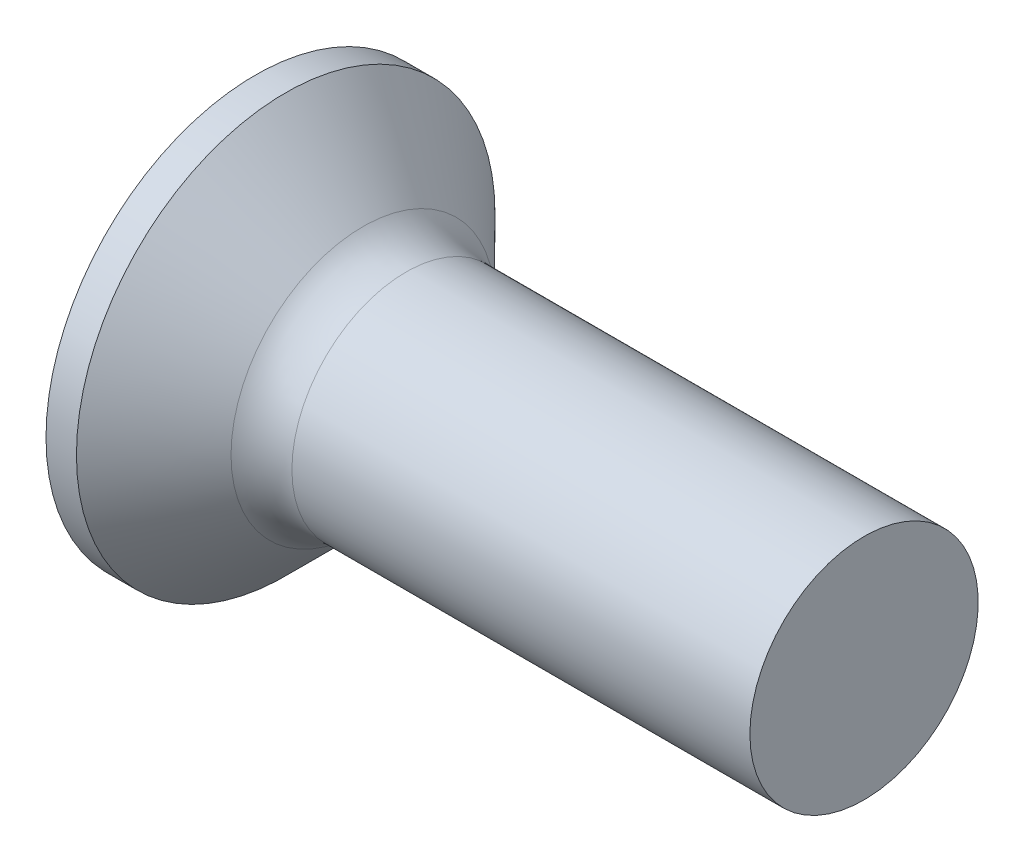
from build123d import *

# Parameters (mm, degrees)
FILLET1_R    = 0.8
SKETCH3_W    = 0.74
SKETCH3_H    = 3
SKETCH4_W    = 0.74
SKETCH4_H    = 0.99570227
RECPAT_COUNT = 2
RECPAT_ANGLE = 90


with BuildPart() as part:
    # BodySke → Base-Revolve (revolve)
    with BuildSketch(Plane.XY):
        Polygon((0, 0), (0, 2.75), (0.4, 2.75), (1.65, 1.5), (8, 1.5), (8, 0), align=None)
    revolve(axis=Axis((-6.35, 0, 0), (1, 0, 0)))

    # Fillet1
    fillet1_edges = [part.edges().sort_by_distance(p)[0] for p in [
        (1.65, -1.5, 0),
    ]]
    fillet(fillet1_edges, radius=FILLET1_R)

    # Sketch3 → Recess section 0
    with BuildSketch(Plane.ZY):
        Rectangle(SKETCH3_W, SKETCH3_H)
    # Sketch4 → Recess section 1
    with BuildSketch(Plane.ZY.offset(-2.01)):
        Rectangle(SKETCH4_W, SKETCH4_H)
    recess = loft(mode=Mode.SUBTRACT)

    # RecPat: Recess ×2 about axis
    recpat_axis = Axis((0, 0, 0), (1, 0, 0))
    for i in range(1, RECPAT_COUNT):
        add(recess.rotate(recpat_axis, i * RECPAT_ANGLE / (RECPAT_COUNT - 1)), mode=Mode.SUBTRACT)

    # RecCorSke → RecessCore (revolve, cut)
    with BuildSketch(Plane.XY):
        Polygon((0, 0), (0, 0.696552892), (2.01, 0.556), (2.190655351, 0), align=None)
    revolve(axis=Axis((-3.175, 0, 0), (1, 0, 0)), mode=Mode.SUBTRACT)


solid = part.part
